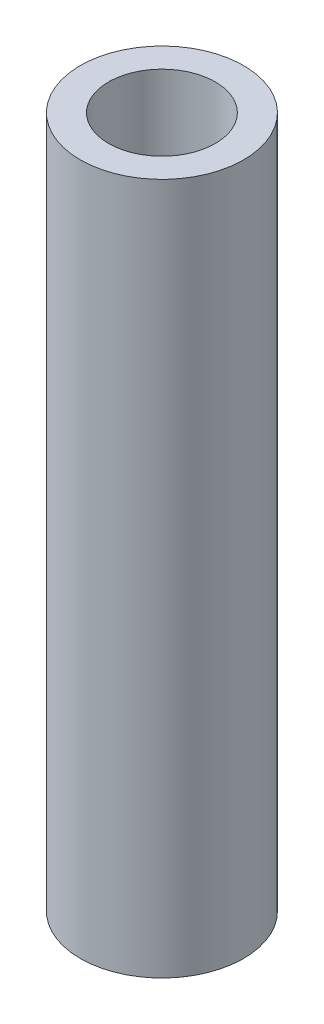
from build123d import *

# Parameters (mm, degrees)
SKETCH1_R           = 3.81
SKETCH1_R_2         = 2.4892
BOSS_EXTRUDE1_DEPTH = 32.258


with BuildPart() as part:
    # Sketch1 → Boss-Extrude1 (new body)
    with BuildSketch(Plane(origin=(0, 0, 0), x_dir=(1, 0, 0), z_dir=(0, 1, 0))):
        Circle(SKETCH1_R)
        Circle(SKETCH1_R_2, mode=Mode.SUBTRACT)
    extrude(amount=BOSS_EXTRUDE1_DEPTH)


solid = part.part
